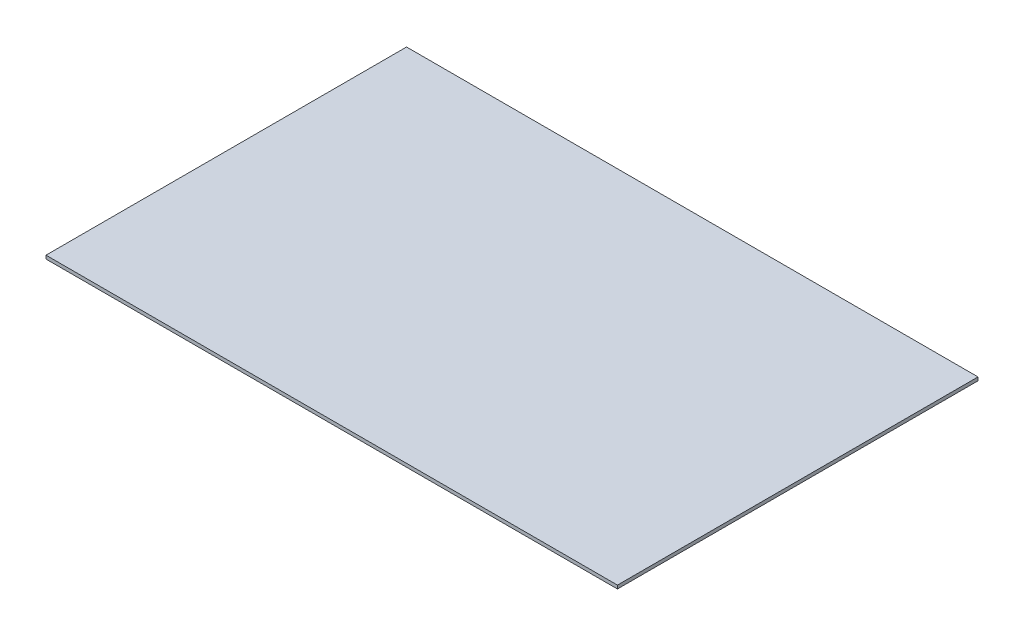
from build123d import *

# Parameters (mm, degrees)
BOSS_EXTRUDE1_DEPTH = 3.175
SKETCH2_W           = 165.1
SKETCH2_H           = 127
BOSS_EXTRUDE2_DEPTH = 3.175


with BuildPart() as part:
    # Sketch1 → Boss-Extrude1 (new body)
    with BuildSketch(Plane(origin=(0, 0, 0), x_dir=(1, 0, 0), z_dir=(0, 1, 0))):
        Polygon((349.25, 336.55), (533.4, 336.55), (533.4, 0), (0, 0), (0, 336.55), (184.15, 336.55), (184.15, 209.55), (349.25, 209.55), align=None)
    extrude(amount=BOSS_EXTRUDE1_DEPTH)

    # Sketch2 → Boss-Extrude2 (add)
    with BuildSketch(Plane(origin=(0, 3.175, 0), x_dir=(1, 0, 0), z_dir=(0, 1, 0))):
        Polygon((184.15, 336.55), (147.800872545, 336.55), (147.800872545, 172.016073561), (409.748972161, 172.016073561), (409.748972161, 336.55), (349.25, 336.55), (349.25, 209.55), (184.15, 209.55), align=None)
        with Locations((266.7, 273.05)):
            Rectangle(SKETCH2_W, SKETCH2_H)
    extrude(amount=-BOSS_EXTRUDE2_DEPTH)


solid = part.part
